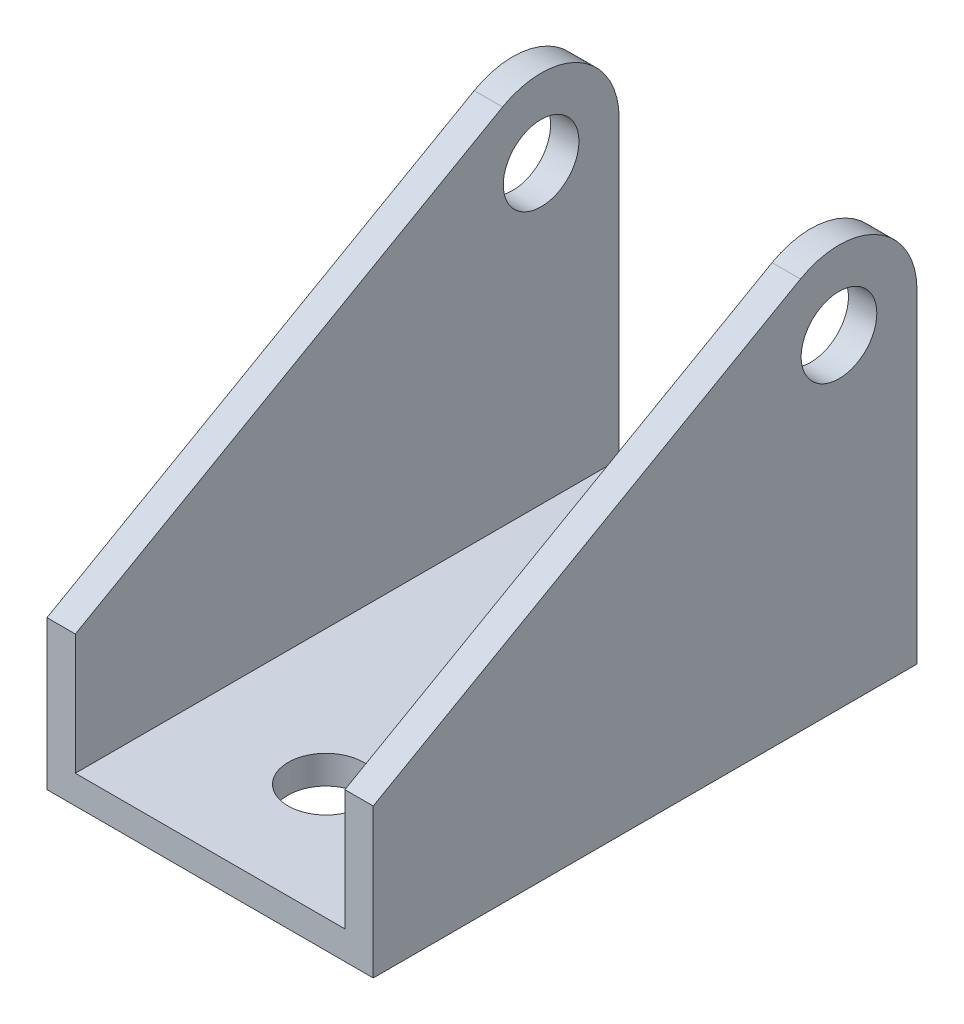
from build123d import *

# Parameters (mm, degrees)
SKETCH1_R               = 4.064
BOSS_EXTRUDE1_DEPTH     = 35.052
SKETCH2_W               = 28.956
SKETCH2_H               = 40.132
CUT_EXTRUDE1_DEPTH      = 59.42
SKETCH3_R               = 4.064
CUT_EXTRUDE3_DEPTH      = 44.18
CUT_EXTRUDE3_DEPTH_BACK = 35.052


with BuildPart() as part:
    # Sketch1 → Boss-Extrude1 (new body)
    with BuildSketch(Plane(origin=(0, 0, 0), x_dir=(0, 0, -1), z_dir=(1, 0, 0))):
        with BuildLine():
            Line((0, 16.002), (45.896514256, 42.085387724))
            ThreePointArc((45.896514256, 42.085387724), (54.253684434, 42.0427173), (58.42, 34.798))
            Line((58.42, 34.798), (58.42, 0))
            Line((58.42, 0), (0, 0))
            Line((0, 0), (0, 16.002))
        make_face()
        with Locations((50.038, 34.798)):
            Circle(SKETCH1_R, mode=Mode.SUBTRACT)
    extrude(amount=-BOSS_EXTRUDE1_DEPTH)

    # Sketch2 → Cut-Extrude1 (cut, through all)
    with BuildSketch(Plane.XY):
        with Locations((-17.526, 23.114)):
            Rectangle(SKETCH2_W, SKETCH2_H)
    extrude(amount=-CUT_EXTRUDE1_DEPTH, mode=Mode.SUBTRACT)

    # Sketch3 → Cut-Extrude3 (cut, two sides)
    with BuildSketch(Plane(origin=(0, 0, 0), x_dir=(1, 0, 0), z_dir=(0, 1, 0))) as cut_extrude3_sk:
        with Locations(Location((-17.526, 12.446, 0), (0, 0, 90))):  # turned: the seam where the file's is
            Circle(SKETCH3_R)
        with BuildLine():
            Line((-21.844, 43.930247399), (-21.844, 58.42))
            Line((-21.844, 58.42), (-13.208, 58.42))
            Line((-13.208, 58.42), (-13.208, 43.930247399))
            ThreePointArc((-13.208, 43.930247399), (-17.526, 39.612247399), (-21.844, 43.930247399))
        make_face()
    extrude(amount=CUT_EXTRUDE3_DEPTH, mode=Mode.SUBTRACT)
    extrude(cut_extrude3_sk.sketch, amount=-CUT_EXTRUDE3_DEPTH_BACK, mode=Mode.SUBTRACT)


solid = part.part
